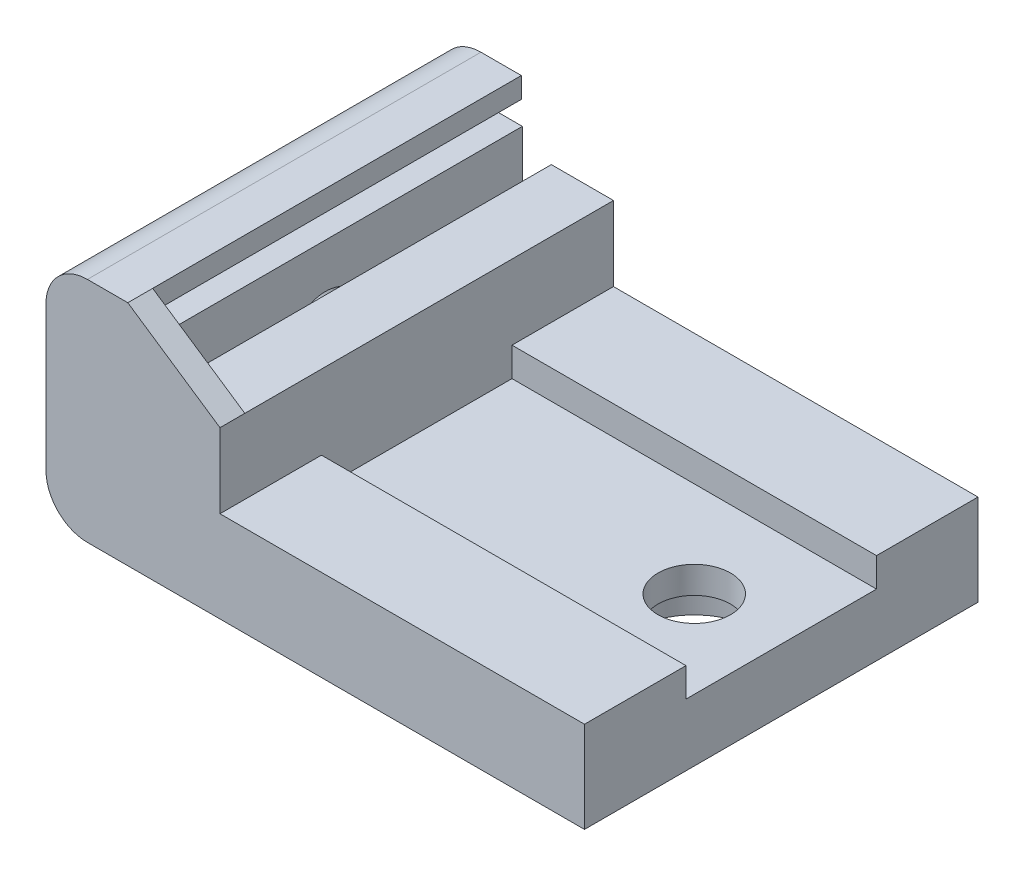
from build123d import *

# Parameters (mm, degrees)
SKETCH2_W           = 23
SKETCH2_H           = 19
BOSS_EXTRUDE1_DEPTH = 3
SKETCH3_W           = 1
SKETCH3_H           = 19
SKETCH3_W_2         = 3
BOSS_EXTRUDE2_DEPTH = 5
BOSS_EXTRUDE3_DEPTH = 19
SKETCH5_R           = 1.75
CUT_EXTRUDE1_DEPTH  = 4
SKETCH6_R           = 3
CUT_EXTRUDE2_DEPTH  = 1.7
SKETCH7_W           = 17.6
SKETCH7_H           = 4.9
BOSS_EXTRUDE4_DEPTH = 1.4
SKETCH8_W           = 2.5
SKETCH8_H           = 0.9
BOSS_EXTRUDE5_DEPTH = 19
SKETCH9_W           = 1.4
SKETCH9_H           = 0.8
CUT_EXTRUDE3_DEPTH  = 20
BOSS_EXTRUDE6_DEPTH = 1.2
CUT_EXTRUDE4_REACH  = 28
SKETCH11_R          = 1.75
FILLET1_R           = 2
FILLET2_R           = 2


with BuildPart() as part:
    # Sketch2 → Boss-Extrude1 (new body)
    with BuildSketch(Plane(origin=(0, 0, 0), x_dir=(1, 0, 0), z_dir=(0, 1, 0))):
        with Locations((11.5, 9.5)):
            Rectangle(SKETCH2_W, SKETCH2_H)
    extrude(amount=BOSS_EXTRUDE1_DEPTH)

    # Sketch3 → Boss-Extrude2 (add)
    with BuildSketch(Plane(origin=(0, 3, 0), x_dir=(1, 0, 0), z_dir=(0, 1, 0))):
        with Locations((0.5, 9.5)):
            Rectangle(SKETCH3_W, SKETCH3_H)
        with Locations((3.9, 9.5)):
            Rectangle(SKETCH3_W_2, SKETCH3_H)
    extrude(amount=BOSS_EXTRUDE2_DEPTH)

    # Sketch4 → Boss-Extrude3 (add)
    with BuildSketch(Plane(origin=(0, 0, -19), x_dir=(-1, 0, 0), z_dir=(0, 0, -1))):
        Polygon((0, 0), (3, 0), (3, 8), (3, 11), (-0.95, 11), (-0.95, 10), (1.5, 10), (1.5, 8), (0, 8), align=None)
    extrude(amount=-BOSS_EXTRUDE3_DEPTH)

    # Sketch5 → Cut-Extrude1 (cut, through all)
    with BuildSketch(Plane(origin=(0, 3, 0), x_dir=(1, 0, 0), z_dir=(0, 1, 0))):
        with Locations((18.8, 9.5)):
            Circle(SKETCH5_R)
    extrude(amount=-CUT_EXTRUDE1_DEPTH, mode=Mode.SUBTRACT)

    # Sketch6 → Cut-Extrude2 (cut)
    with BuildSketch(Plane.XZ):
        with Locations((18.8, -9.5)):
            Circle(SKETCH6_R)
    extrude(amount=-CUT_EXTRUDE2_DEPTH, mode=Mode.SUBTRACT)

    # Sketch7 → Boss-Extrude4 (add)
    with BuildSketch(Plane(origin=(0, 3, 0), x_dir=(1, 0, 0), z_dir=(0, 1, 0))):
        with Locations((14.2, 2.45)):
            Rectangle(SKETCH7_W, SKETCH7_H)
        with Locations((14.2, 16.55)):
            Rectangle(SKETCH7_W, SKETCH7_H)
    extrude(amount=BOSS_EXTRUDE4_DEPTH)

    # Sketch8 → Boss-Extrude5 (add)
    with BuildSketch(Plane(origin=(0, 0, -19), x_dir=(-1, 0, 0), z_dir=(0, 0, -1))):
        with Locations((0.25, 8.45)):
            Rectangle(SKETCH8_W, SKETCH8_H)
    extrude(amount=-BOSS_EXTRUDE5_DEPTH)

    # Sketch9 → Cut-Extrude3 (cut, through all)
    with BuildSketch(Plane(origin=(0, 0, -19), x_dir=(-1, 0, 0), z_dir=(0, 0, -1))):
        with Locations((-1.7, 2.6)):
            Rectangle(SKETCH9_W, SKETCH9_H)
    extrude(amount=-CUT_EXTRUDE3_DEPTH, mode=Mode.SUBTRACT)

    # Sketch10 → Boss-Extrude6 (add)
    with BuildSketch(Plane.XY):
        Polygon((-1.5, 8.9), (-1.5, 10), (0.95, 10), (0.95, 11), (5.4, 8), (2.4, 8), (2.4, 2.2), (1, 2.2), (1, 8.9), align=None)
    extrude(amount=-BOSS_EXTRUDE6_DEPTH)

    # Sketch11 → Cut-Extrude4 (cut, up to next)
    with BuildSketch(Plane.ZY.offset(3), mode=Mode.PRIVATE) as cut_extrude4_sk1:
        with Locations((-9.5, 5)):
            Circle(SKETCH11_R)
    cut_extrude4_tool1 = extrude(cut_extrude4_sk1.sketch, amount=-CUT_EXTRUDE4_REACH, mode=Mode.PRIVATE) & part.part
    add(cut_extrude4_tool1.solids().sort_by_distance((-3, 5, -9.5))[0], mode=Mode.SUBTRACT)

    # Fillet1
    fillet1_edges = [part.edges().sort_by_distance(p)[0] for p in [
        (-3, 11, -9.5),
    ]]
    fillet(fillet1_edges, radius=FILLET1_R)

    # Fillet2
    fillet2_edges = [part.edges().sort_by_distance(p)[0] for p in [
        (-3, 0, -9.5),
    ]]
    fillet(fillet2_edges, radius=FILLET2_R)


solid = part.part
